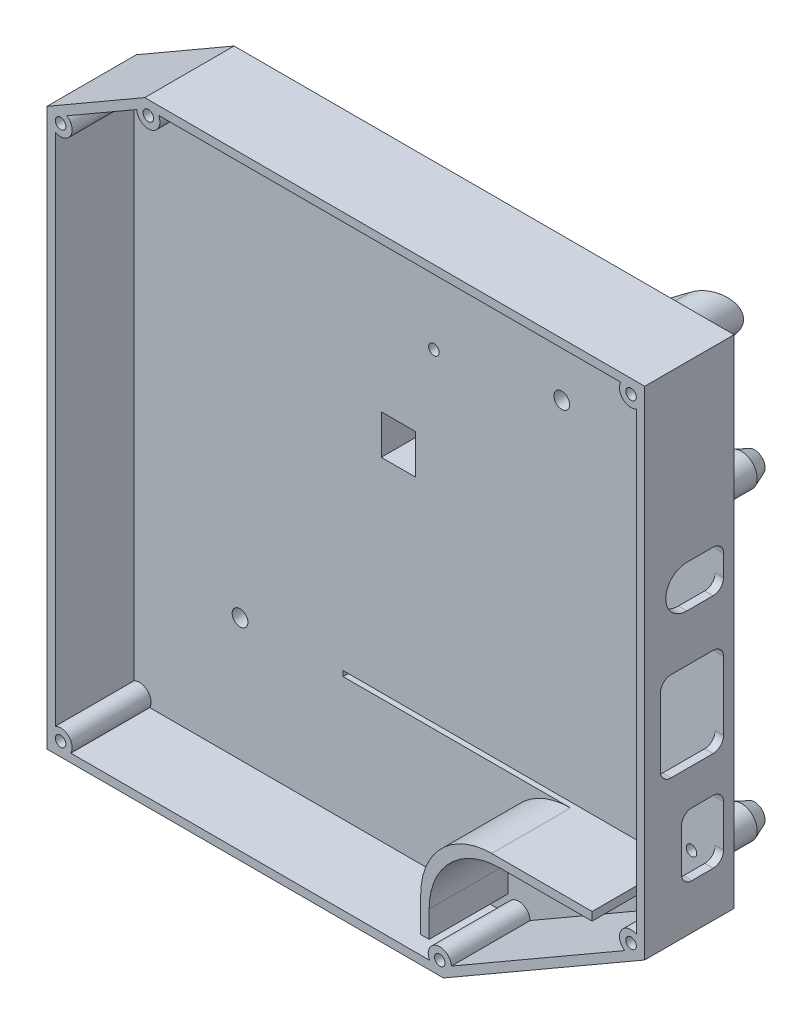
from build123d import *
from build123d.topology import SkipClean

# Parameters (mm, degrees)
SKETCH2_R                = 1
SKETCH2_W                = 6.5
SKETCH2_H                = 7.5
BOSS_EXTRUDE1_DEPTH      = 2
SKETCH3_R                = 2
SKETCH3_R_2              = 1
SKETCH3_W                = 8.5
SKETCH3_H                = 9.5
SKETCH3_W_2              = 6.5
SKETCH3_H_2              = 7.5
BOSS_EXTRUDE2_DEPTH      = 7
SKETCH4_R                = 1
SKETCH4_W                = 62.35
SKETCH4_H                = 1
SKETCH4_W_2              = 6.5
SKETCH4_H_2              = 7.5
BOSS_EXTRUDE4_DEPTH      = 2
SKETCH5_R                = 1
BOSS_EXTRUDE5_DEPTH      = 15
BOSS_EXTRUDE6_REACH      = 296.536
BOSS_EXTRUDE6_END_RADIUS = 62
SKETCH6_R                = 1.5
SKETCH7_R                = 1
SKETCH7_W                = 6.5
SKETCH7_H                = 7.5
BOSS_EXTRUDE7_DEPTH      = 7
SKETCH13_R               = 1.5
CUT_EXTRUDE3_DEPTH       = 296.430370392
CUT_EXTRUDE3_DEPTH_BACK  = 296.430370392
CUT_EXTRUDE4_DEPTH       = 1.6


with BuildPart() as part:
    # Sketch2 → Boss-Extrude1 (new body)
    with BuildSketch(Plane.XY.offset(8)):
        Polygon((-25, 200), (-9.5, 200), (-9.5, 204), (9.5, 204), (13.5, 200), (25, 200), (25, 255), (-25, 255), align=None)
        with Locations((10.5, 218.75)):
            Circle(SKETCH2_R, mode=Mode.SUBTRACT)
        with Locations((17, 246.25)):
            Circle(SKETCH2_R, mode=Mode.SUBTRACT)
        with Locations((-16, 246.25)):
            Circle(SKETCH2_R, mode=Mode.SUBTRACT)
        with Locations((17, 208.75)):
            Circle(SKETCH2_R, mode=Mode.SUBTRACT)
        with Locations((-16, 208.75)):
            Circle(SKETCH2_R, mode=Mode.SUBTRACT)
        with Locations((10.5, 231.25)):
            Circle(SKETCH2_R, mode=Mode.SUBTRACT)
        with Locations(Location((-10.5, 218.75, 0), (0, 0, 180))):
            Circle(SKETCH2_R, mode=Mode.SUBTRACT)
        with Locations(Location((-10.5, 231.25, 0), (0, 0, 180))):
            Circle(SKETCH2_R, mode=Mode.SUBTRACT)
        with Locations((1, 239.25)):
            Rectangle(SKETCH2_W, SKETCH2_H, mode=Mode.SUBTRACT)
    extrude(amount=BOSS_EXTRUDE1_DEPTH)

    # Sketch3 → Boss-Extrude2 (add)
    with BuildSketch(Plane.XY.offset(10)):
        with Locations((-16, 246.25)):
            Circle(SKETCH3_R)
        with Locations((-16, 246.25)):
            Circle(SKETCH3_R_2, mode=Mode.SUBTRACT)
        with Locations((-10.5, 231.25)):
            Circle(SKETCH3_R)
        with Locations(Location((-10.5, 231.25, 0), (0, 0, 180))):
            Circle(SKETCH3_R_2, mode=Mode.SUBTRACT)
        with Locations((-10.5, 218.75)):
            Circle(SKETCH3_R)
        with Locations(Location((-10.5, 218.75, 0), (0, 0, 180))):
            Circle(SKETCH3_R_2, mode=Mode.SUBTRACT)
        with Locations((-16, 208.75)):
            Circle(SKETCH3_R)
        with Locations((-16, 208.75)):
            Circle(SKETCH3_R_2, mode=Mode.SUBTRACT)
        with Locations((17, 208.75)):
            Circle(SKETCH3_R)
        with Locations((17, 208.75)):
            Circle(SKETCH3_R_2, mode=Mode.SUBTRACT)
        with Locations((10.5, 218.75)):
            Circle(SKETCH3_R)
        with Locations((10.5, 218.75)):
            Circle(SKETCH3_R_2, mode=Mode.SUBTRACT)
        with Locations((10.5, 231.25)):
            Circle(SKETCH3_R)
        with Locations((10.5, 231.25)):
            Circle(SKETCH3_R_2, mode=Mode.SUBTRACT)
        with Locations((17, 246.25)):
            Circle(SKETCH3_R)
        with Locations((17, 246.25)):
            Circle(SKETCH3_R_2, mode=Mode.SUBTRACT)
        with Locations((1, 239.25)):
            Rectangle(SKETCH3_W, SKETCH3_H)
        with Locations((1, 239.25)):
            Rectangle(SKETCH3_W_2, SKETCH3_H_2, mode=Mode.SUBTRACT)
    extrude(amount=BOSS_EXTRUDE2_DEPTH)

    # Sketch4 → Boss-Extrude4 (add)
    with BuildSketch(Plane.XY.offset(17)):
        Polygon((-50.85, 276.511284993), (-32.25, 287.25), (62.85, 287.25), (62.85, 192.75), (24.571677153, 170.65), (-50.85, 170.65), align=None)
        with Locations((7.75, 258.25)):
            Circle(SKETCH4_R, mode=Mode.SUBTRACT)
        with Locations((56.75, 258.25)):
            Circle(SKETCH4_R, mode=Mode.SUBTRACT)
        with Locations((56.75, 200.25)):
            Circle(SKETCH4_R, mode=Mode.SUBTRACT)
        with Locations((21.675, 196.25)):
            Rectangle(SKETCH4_W, SKETCH4_H, mode=Mode.SUBTRACT)
        with Locations((1, 239.25)):
            Rectangle(SKETCH4_W_2, SKETCH4_H_2, mode=Mode.SUBTRACT)
    extrude(amount=BOSS_EXTRUDE4_DEPTH)

    # Sketch5 → Boss-Extrude5 (add)
    with BuildSketch(Plane.XY.offset(19)):
        Polygon((-50.85, 170.65), (24.571677153, 170.65), (62.85, 192.75), (62.85, 287.25), (-32.25, 287.25), (-50.85, 276.511284993), align=None)
        with Locations((-48.25, 275.010174293)):
            Circle(SKETCH5_R, mode=Mode.SUBTRACT)
        with Locations((-48.25, 173.25)):
            Circle(SKETCH5_R, mode=Mode.SUBTRACT)
        with Locations((23.875009252, 173.25)):
            Circle(SKETCH5_R, mode=Mode.SUBTRACT)
        with Locations((60.25, 284.65)):
            Circle(SKETCH5_R, mode=Mode.SUBTRACT)
        with Locations((60.25, 194.2511107)):
            Circle(SKETCH5_R, mode=Mode.SUBTRACT)
        with Locations((-31.5533321, 284.65)):
            Circle(SKETCH5_R, mode=Mode.SUBTRACT)
        with BuildLine():
            Line((-47.052943725, 276.855995594), (-33.750388375, 284.536229507))
            ThreePointArc((-33.750388375, 284.536229507), (-30.9839302, 282.524963182), (-29.593740305, 285.65))
            Line((-29.593740305, 285.65), (58.290408206, 285.65))
            ThreePointArc((58.290408206, 285.65), (58.694365081, 283.094365081), (61.25, 282.690408206))
            Line((61.25, 282.690408206), (61.25, 196.210702494))
            ThreePointArc((61.25, 196.210702494), (58.344744112, 195.3511107), (59.052943725, 192.405289399))
            Line((59.052943725, 192.405289399), (26.072065527, 173.363770493))
            ThreePointArc((26.072065527, 173.363770493), (23.305607353, 175.375036818), (21.915417458, 172.25))
            Line((21.915417458, 172.25), (-46.290408206, 172.25))
            ThreePointArc((-46.290408206, 172.25), (-46.694365081, 174.805634919), (-49.25, 175.209591794))
            Line((-49.25, 175.209591794), (-49.25, 273.050582499))
            ThreePointArc((-49.25, 273.050582499), (-46.344744112, 273.910174293), (-47.052943725, 276.855995594))
        make_face(mode=Mode.SUBTRACT)
        with BuildLine():
            Line((20.25, 182.25), (20.25, 175.65))
            Line((20.25, 175.65), (21.85, 175.65))
            Line((21.85, 175.65), (21.85, 180.65))
            ThreePointArc((21.85, 180.65), (25.804058454, 190.195941546), (35.35, 194.15))
            Line((35.35, 194.15), (52.85, 194.15))
            Line((52.85, 194.15), (52.85, 195.75))
            Line((52.85, 195.75), (33.75, 195.75))
            ThreePointArc((33.75, 195.75), (24.204058454, 191.795941546), (20.25, 182.25))
        make_face()
    extrude(amount=BOSS_EXTRUDE5_DEPTH)

    # Boss-Extrude6: up to this cylinder (the profile starts outside it)
    boss_extrude6_end = Plane(origin=(0, 227.2179875, -62), z_dir=(0, -1, 0)) * Cylinder(BOSS_EXTRUDE6_END_RADIUS, 775.411717, mode=Mode.PRIVATE)
    # Sketch6 → Boss-Extrude6 (add, up to the surface)
    with BuildSketch(Plane(origin=(0, 0, 17), x_dir=(-1, 0, 0), z_dir=(0, 0, -1)), mode=Mode.PRIVATE) as boss_extrude6_sk1:
        with BuildLine():
            ThreePointArc((26.2, 207.639829809), (25.301967581, 211.271323786), (25, 215))
            Line((25, 215), (25, 200))
            Line((25, 200), (9.5, 200))
            ThreePointArc((9.5, 200), (13.228676214, 199.698032419), (16.860170191, 198.8))
            ThreePointArc((16.860170191, 198.8), (21.903647625, 196.400660159), (26.226520034, 192.864239591))
            ThreePointArc((26.226520034, 192.864239591), (31.923887432, 192.785663344), (31.919457252, 198.483570842))
            ThreePointArc((31.919457252, 198.483570842), (28.519048576, 202.723964527), (26.2, 207.639829809))
        make_face()
        with Locations(Location((29.113923624, 195.63243404, 0), (0, 0, 180))):
            Circle(SKETCH6_R, mode=Mode.SUBTRACT)
    boss_extrude6_tool1 = extrude(boss_extrude6_sk1.sketch, amount=BOSS_EXTRUDE6_REACH, mode=Mode.PRIVATE) - boss_extrude6_end
    add(boss_extrude6_tool1.solids().sort_by_distance((-26.163213, 198.548129, 17))[0])
    # Sketch6 → Boss-Extrude6 (add, up to the surface)
    with BuildSketch(Plane(origin=(0, 0, 17), x_dir=(-1, 0, 0), z_dir=(0, 0, -1)), mode=Mode.PRIVATE) as boss_extrude6_sk2:
        with BuildLine():
            Line((25, 255), (25, 215))
            ThreePointArc((25, 215), (25.301967581, 211.271323786), (26.2, 207.639829809))
            Line((26.2, 207.639829809), (26.2, 256.2))
            Line((26.2, 256.2), (-7.296447768, 256.2))
            ThreePointArc((-7.296447768, 256.2), (-1.177431257, 255.300710892), (5, 255))
            Line((5, 255), (25, 255))
        make_face()
    boss_extrude6_tool2 = extrude(boss_extrude6_sk2.sketch, amount=BOSS_EXTRUDE6_REACH, mode=Mode.PRIVATE) - boss_extrude6_end
    add(boss_extrude6_tool2.solids().sort_by_distance((1.120133, 255.887846, 17))[0])
    # Sketch6 → Boss-Extrude6 (add, up to the surface)
    with BuildSketch(Plane(origin=(0, 0, 17), x_dir=(-1, 0, 0), z_dir=(0, 0, -1)), mode=Mode.PRIVATE) as boss_extrude6_sk3:
        with BuildLine():
            ThreePointArc((16.860170191, 198.8), (13.228676214, 199.698032419), (9.5, 200))
            Line((9.5, 200), (9.5, 198.8))
            Line((9.5, 198.8), (16.860170191, 198.8))
        make_face()
    boss_extrude6_tool3 = extrude(boss_extrude6_sk3.sketch, amount=BOSS_EXTRUDE6_REACH, mode=Mode.PRIVATE) - boss_extrude6_end
    add(boss_extrude6_tool3.solids().sort_by_distance((-12.26985, 199.281082, 17))[0])
    # Sketch6 → Boss-Extrude6 (add, up to the surface)
    with BuildSketch(Plane(origin=(0, 0, 17), x_dir=(-1, 0, 0), z_dir=(0, 0, -1)), mode=Mode.PRIVATE) as boss_extrude6_sk4:
        with BuildLine():
            Line((-25, 255), (5, 255))
            ThreePointArc((5, 255), (-1.177431257, 255.300710892), (-7.296447768, 256.2))
            ThreePointArc((-7.296447768, 256.2), (-19.032896026, 259.715449952), (-29.877549031, 265.415985652))
            ThreePointArc((-29.877549031, 265.415985652), (-34.899494937, 264.899494937), (-35.415985652, 259.877549031))
            ThreePointArc((-35.415985652, 259.877549031), (-29.715449952, 249.032896026), (-26.2, 237.296447768))
            ThreePointArc((-26.2, 237.296447768), (-25.300710892, 231.177431257), (-25, 225))
            Line((-25, 225), (-25, 255))
        make_face()
        with Locations(Location((-32.071067812, 262.071067812, 0), (0, 0, 180))):
            Circle(SKETCH6_R, mode=Mode.SUBTRACT)
    boss_extrude6_tool4 = extrude(boss_extrude6_sk4.sketch, amount=BOSS_EXTRUDE6_REACH, mode=Mode.PRIVATE) - boss_extrude6_end
    add(boss_extrude6_tool4.solids().sort_by_distance((25.351831, 255.351831, 17))[0])
    # Sketch6 → Boss-Extrude6 (add, up to the surface)
    with BuildSketch(Plane(origin=(0, 0, 17), x_dir=(-1, 0, 0), z_dir=(0, 0, -1)), mode=Mode.PRIVATE) as boss_extrude6_sk5:
        with BuildLine():
            Line((-25, 200), (-25, 225))
            ThreePointArc((-25, 225), (-25.300710892, 231.177431257), (-26.2, 237.296447768))
            Line((-26.2, 237.296447768), (-26.2, 198.8))
            Line((-26.2, 198.8), (-14.7, 198.8))
            Line((-14.7, 198.8), (-13.5, 200))
            Line((-13.5, 200), (-25, 200))
        make_face()
    boss_extrude6_tool5 = extrude(boss_extrude6_sk5.sketch, amount=BOSS_EXTRUDE6_REACH, mode=Mode.PRIVATE) - boss_extrude6_end
    add(boss_extrude6_tool5.solids().sort_by_distance((25.405372, 212.5, 17))[0])

    # Sketch7 → Boss-Extrude7 (add)
    with BuildSketch(Plane.XY.offset(10)):
        Polygon((13.5, 200), (25, 200), (25, 255), (-25, 255), (-25, 200), (-9.5, 200), (-9.5, 204), (9.5, 204), align=None)
        with Locations((-16, 208.75)):
            Circle(SKETCH7_R, mode=Mode.SUBTRACT)
        with Locations(Location((-10.5, 218.75, 0), (0, 0, 180))):
            Circle(SKETCH7_R, mode=Mode.SUBTRACT)
        with Locations((17, 208.75)):
            Circle(SKETCH7_R, mode=Mode.SUBTRACT)
        with Locations((10.5, 218.75)):
            Circle(SKETCH7_R, mode=Mode.SUBTRACT)
        with Locations((17, 246.25)):
            Circle(SKETCH7_R, mode=Mode.SUBTRACT)
        with Locations((10.5, 231.25)):
            Circle(SKETCH7_R, mode=Mode.SUBTRACT)
        with Locations(Location((-10.5, 231.25, 0), (0, 0, 180))):
            Circle(SKETCH7_R, mode=Mode.SUBTRACT)
        with Locations((-16, 246.25)):
            Circle(SKETCH7_R, mode=Mode.SUBTRACT)
        with Locations((1, 239.25)):
            Rectangle(SKETCH7_W, SKETCH7_H, mode=Mode.SUBTRACT)
    extrude(amount=BOSS_EXTRUDE7_DEPTH)

    # Sketch8 → Revolve1 (revolve)
    with BuildSketch(Plane(origin=(7.75, 0, 0), x_dir=(0, 0, -1), z_dir=(1, 0, 0)), mode=Mode.PRIVATE) as revolve1_sk:
        Polygon((-6.999998642, 259.25), (-6.999998642, 260.25), (-9.499999321, 261.25), (-14.499999321, 261.25), (-17, 262.25), (-17, 259.25), align=None)
    revolve(revolve1_sk.sketch.rotate(Axis((7.75, 258.25, 17), (0, 0, -1)), 90), axis=Axis((7.75, 258.25, 17), (0, 0, -1)))

    # Sketch9 → Revolve3 (revolve)
    with BuildSketch(Plane(origin=(56.75, 0, 0), x_dir=(0, 0, -1), z_dir=(1, 0, 0)), mode=Mode.PRIVATE) as revolve3_sk:
        Polygon((-6.999998642, 259.25), (-6.999998642, 260.25), (-9.499999321, 261.25), (-14.499999321, 261.25), (-17, 262.25), (-17, 259.25), align=None)
    revolve(revolve3_sk.sketch.rotate(Axis((56.75, 258.25, 17), (0, 0, -1)), 90), axis=Axis((56.75, 258.25, 17), (0, 0, -1)))

    # Sketch10 → Revolve4 (revolve)
    with SkipClean():  # the faces are left unmerged after this step: merging them gives an invalid solid
        with BuildSketch(Plane(origin=(0, 200.25, 0), x_dir=(-1, 0, 0), z_dir=(0, -1, 0))):
            Polygon((-55.75, -6.999998642), (-55.75, -17), (-52.75, -17), (-53.75, -14.499999321), (-53.75, -9.499999321), (-54.75, -6.999998642), align=None)
        revolve(axis=Axis((56.75, 200.25, 6.999998642), (0, 0, 1)))

    # Sketch13 → Cut-Extrude3 (cut, two sides)
    with BuildSketch(Plane(origin=(0, 0, 17), x_dir=(-1, 0, 0), z_dir=(0, 0, -1))) as cut_extrude3_sk:
        with Locations(Location((-32.071067812, 262.071067812, 0), (0, 0, 180))):
            Circle(SKETCH13_R)
        with Locations(Location((29.113923624, 195.63243404, 0), (0, 0, 180))):
            Circle(SKETCH13_R)
    extrude(amount=CUT_EXTRUDE3_DEPTH, mode=Mode.SUBTRACT)
    extrude(cut_extrude3_sk.sketch, amount=-CUT_EXTRUDE3_DEPTH_BACK, mode=Mode.SUBTRACT)

    # Sketch14 → Cut-Extrude4 (cut)
    with BuildSketch(Plane(origin=(62.85, 0, 0), x_dir=(0, 0, -1), z_dir=(1, 0, 0))):
        with BuildLine():
            Line((-26, 254.25), (-21, 254.25))
            ThreePointArc((-21, 254.25), (-19.585786438, 253.664213562), (-19, 252.25))
            Line((-19, 252.25), (-19, 248.25))
            ThreePointArc((-19, 248.25), (-19.585786438, 246.835786438), (-21, 246.25))
            Line((-21, 246.25), (-26, 246.25))
            ThreePointArc((-26, 246.25), (-30, 250.25), (-26, 254.25))
        make_face()
        with BuildLine():
            Line((-21, 213.35), (-25, 213.35))
            ThreePointArc((-25, 213.35), (-26.414213562, 212.764213562), (-27, 211.35))
            Line((-27, 211.35), (-27, 203.35))
            ThreePointArc((-27, 203.35), (-26.414213562, 201.935786438), (-25, 201.35))
            Line((-25, 201.35), (-21, 201.35))
            ThreePointArc((-21, 201.35), (-19.585786438, 201.935786438), (-19, 203.35))
            Line((-19, 203.35), (-19, 211.35))
            ThreePointArc((-19, 211.35), (-19.585786438, 212.764213562), (-21, 213.35))
        make_face()
        with BuildLine():
            Line((-29, 237.25), (-21, 237.25))
            ThreePointArc((-21, 237.25), (-19.585786438, 236.664213562), (-19, 235.25))
            Line((-19, 235.25), (-19, 222.25))
            ThreePointArc((-19, 222.25), (-19.585786438, 220.835786438), (-21, 220.25))
            Line((-21, 220.25), (-29, 220.25))
            ThreePointArc((-29, 220.25), (-30.414213562, 220.835786438), (-31, 222.25))
            Line((-31, 222.25), (-31, 235.25))
            ThreePointArc((-31, 235.25), (-30.414213562, 236.664213562), (-29, 237.25))
        make_face()
    extrude(amount=-CUT_EXTRUDE4_DEPTH, mode=Mode.SUBTRACT)


solid = part.part
